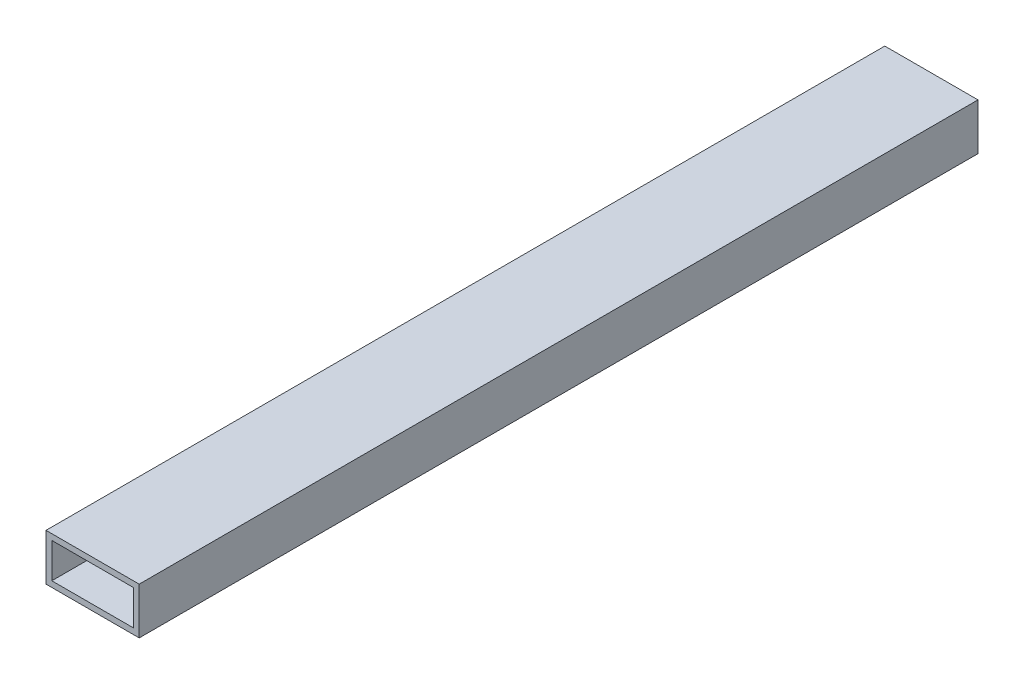
from build123d import *

# Parameters (mm, degrees)
SKETCH1_W           = 101.6
SKETCH1_H           = 50.8
SKETCH1_W_2         = 88.9
SKETCH1_H_2         = 38.1
BOSS_EXTRUDE1_DEPTH = 457.2
SKETCH4_W           = 25.4
SKETCH4_H           = 50.8
BOSS_EXTRUDE3_DEPTH = 0.0254


with BuildPart() as part:
    # Sketch1 → Boss-Extrude1 (new body, symmetric)
    with BuildSketch(Plane.XY):
        Rectangle(SKETCH1_W, SKETCH1_H)
        Rectangle(SKETCH1_W_2, SKETCH1_H_2, mode=Mode.SUBTRACT)
    extrude(amount=BOSS_EXTRUDE1_DEPTH, both=True)

    # Sketch4 → Boss-Extrude3 (add)
    with BuildSketch(Plane.ZY.offset(50.8)):
        Rectangle(SKETCH4_W, SKETCH4_H)
    extrude(amount=BOSS_EXTRUDE3_DEPTH)


solid = part.part
